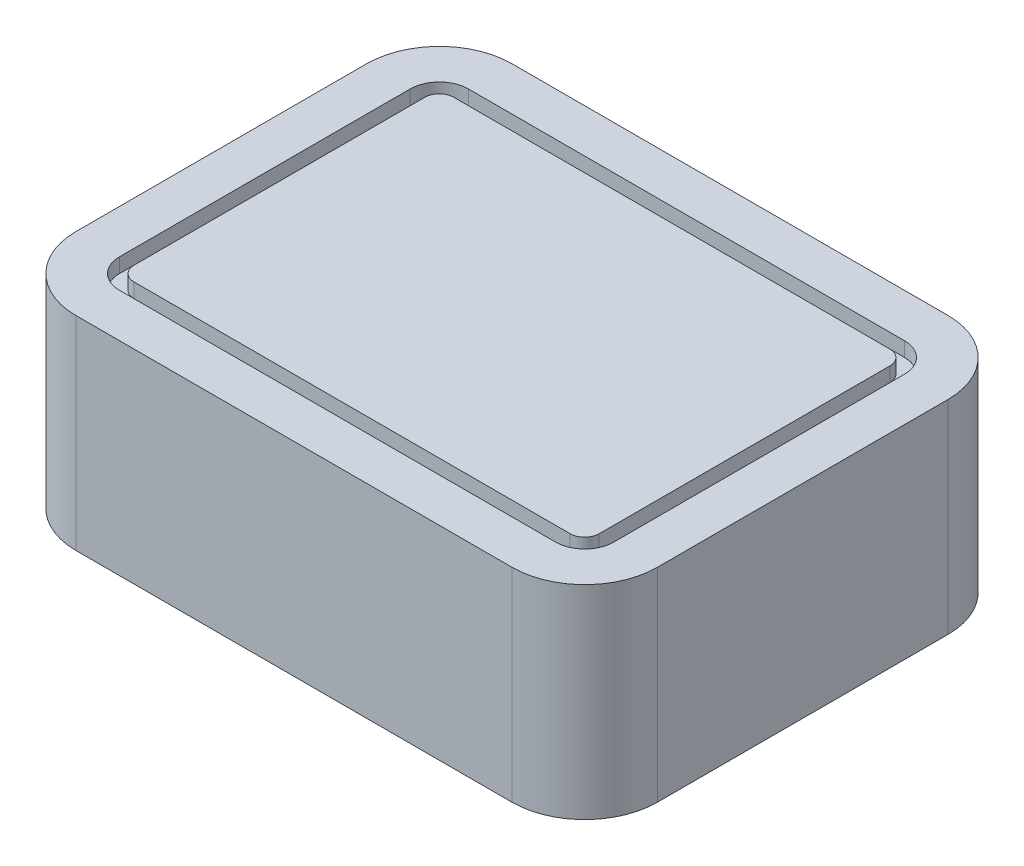
from build123d import *

# Parameters (mm, degrees)
SKETCH1_W           = 40
SKETCH1_H           = 30
BOSS_EXTRUDE1_DEPTH = 14
FILLET1_R           = 5
CUT_EXTRUDE1_DEPTH  = 1


with BuildPart() as part:
    # Sketch1 → Boss-Extrude1 (new body)
    with BuildSketch(Plane(origin=(0, 0, 0), x_dir=(1, 0, 0), z_dir=(0, 1, 0))):
        Rectangle(SKETCH1_W, SKETCH1_H)
    extrude(amount=BOSS_EXTRUDE1_DEPTH)

    # Fillet1
    fillet1_edges = [part.edges().sort_by_distance(p)[0] for p in [
        (20, 7, 15),
        (-20, 7, 15),
        (-20, 7, -15),
        (20, 7, -15),
    ]]
    fillet(fillet1_edges, radius=FILLET1_R)

    # Sketch2 → Cut-Extrude1 (cut)
    with BuildSketch(Plane(origin=(0, 14, 0), x_dir=(1, 0, 0), z_dir=(0, 1, 0))):
        with BuildLine():
            Line((15, 12), (-15, 12))
            ThreePointArc((-15, 12), (-16.414213562, 11.414213562), (-17, 10))
            Line((-17, 10), (-17, -10))
            ThreePointArc((-17, -10), (-16.414213562, -11.414213562), (-15, -12))
            Line((-15, -12), (15, -12))
            ThreePointArc((15, -12), (16.414213562, -11.414213562), (17, -10))
            Line((17, -10), (17, 10))
            ThreePointArc((17, 10), (16.414213562, 11.414213562), (15, 12))
        make_face()
        with BuildLine():
            Line((15, 11), (-15, 11))
            ThreePointArc((-15, 11), (-15.707106781, 10.707106781), (-16, 10))
            Line((-16, 10), (-16, -10))
            ThreePointArc((-16, -10), (-15.707106781, -10.707106781), (-15, -11))
            Line((-15, -11), (15, -11))
            ThreePointArc((15, -11), (15.707106781, -10.707106781), (16, -10))
            Line((16, -10), (16, 10))
            ThreePointArc((16, 10), (15.707106781, 10.707106781), (15, 11))
        make_face(mode=Mode.SUBTRACT)
    extrude(amount=-CUT_EXTRUDE1_DEPTH, mode=Mode.SUBTRACT)


solid = part.part
